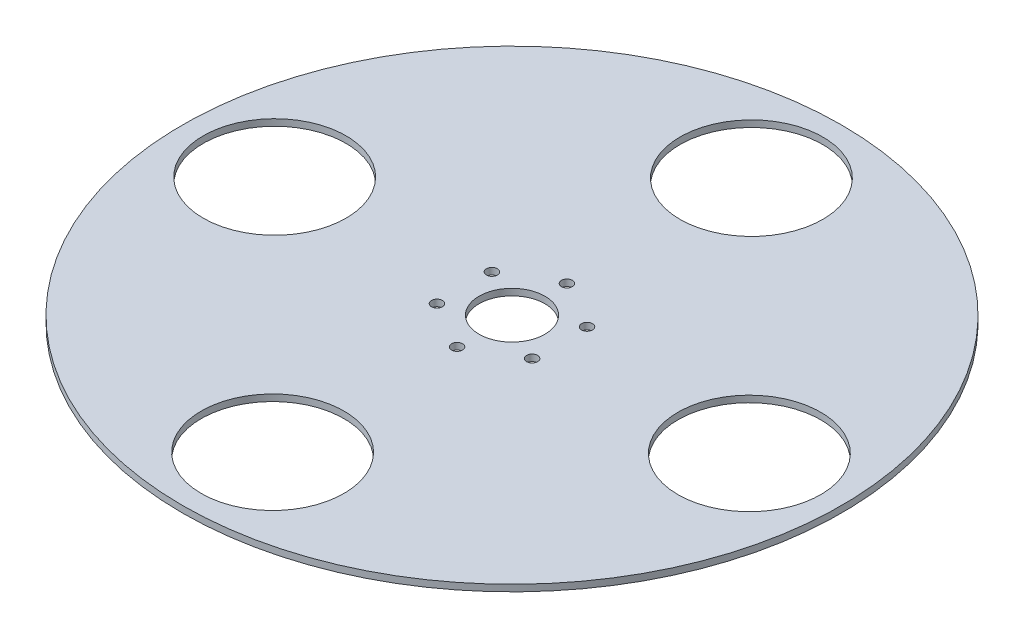
from build123d import *

# Parameters (mm, degrees)
SKETCH1_R           = 150
SKETCH1_R_2         = 15
SKETCH1_R_3         = 2.5
SKETCH1_R_4         = 32.5
BOSS_EXTRUDE1_DEPTH = 3


with BuildPart() as part:
    # Sketch1 → Boss-Extrude1 (new body)
    with BuildSketch(Plane(origin=(0, 0, 0), x_dir=(1, 0, 0), z_dir=(0, 1, 0))):
        Circle(SKETCH1_R)
        Circle(SKETCH1_R_2, mode=Mode.SUBTRACT)
        with Locations((0, 25)):
            Circle(SKETCH1_R_3, mode=Mode.SUBTRACT)
        with Locations((21.650635095, 12.5)):
            Circle(SKETCH1_R_3, mode=Mode.SUBTRACT)
        with Locations((21.650635095, -12.5)):
            Circle(SKETCH1_R_3, mode=Mode.SUBTRACT)
        with Locations((0, -25)):
            Circle(SKETCH1_R_3, mode=Mode.SUBTRACT)
        with Locations((-21.650635095, -12.5)):
            Circle(SKETCH1_R_3, mode=Mode.SUBTRACT)
        with Locations((-21.650635095, 12.5)):
            Circle(SKETCH1_R_3, mode=Mode.SUBTRACT)
        with Locations((0.468706939, 108.498987616)):
            Circle(SKETCH1_R_4, mode=Mode.SUBTRACT)
        with Locations((108.498987616, -0.468706939)):
            Circle(SKETCH1_R_4, mode=Mode.SUBTRACT)
        with Locations((-0.468706939, -108.498987616)):
            Circle(SKETCH1_R_4, mode=Mode.SUBTRACT)
        with Locations((-108.498987616, 0.468706939)):
            Circle(SKETCH1_R_4, mode=Mode.SUBTRACT)
    extrude(amount=BOSS_EXTRUDE1_DEPTH)


solid = part.part
